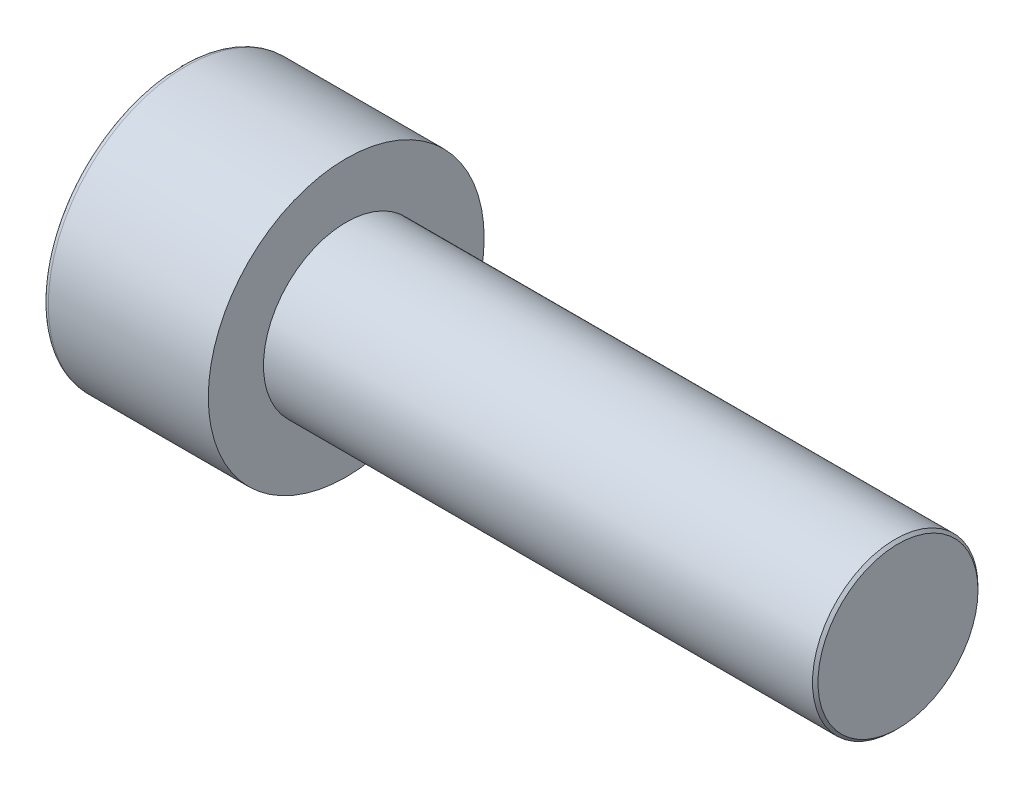
from build123d import *

# Parameters (mm, degrees)
SKETCH1_R           = 5
BASEHEAD_DEPTH      = 6
SKETCH2_R           = 3
BASEBODY_DEPTH      = 20
HEXAGONSOCKET_DEPTH = 3
TOPFILLET_R         = 0.2
CHAMFER1_SIZE       = 0.1


with BuildPart() as part:
    # Sketch1 → BaseHead (new body)
    with BuildSketch(Plane(origin=(0, 0, 0), x_dir=(0, 0, -1), z_dir=(1, 0, 0))):
        Circle(SKETCH1_R)
    extrude(amount=BASEHEAD_DEPTH)

    # Sketch2 → BaseBody (add)
    with BuildSketch(Plane(origin=(6, 0, 0), x_dir=(0, 0, -1), z_dir=(1, 0, 0))):
        Circle(SKETCH2_R)
    extrude(amount=BASEBODY_DEPTH)

    # Sketch3 → HexagonSocket (cut)
    with BuildSketch(Plane(origin=(0, 0, 0), x_dir=(0, 0, -1), z_dir=(1, 0, 0))):
        Polygon((2.886751346, 0), (1.443375673, 2.5), (-1.443375673, 2.5), (-2.886751346, 0), (-1.443375673, -2.5), (1.443375673, -2.5), align=None)
    extrude(amount=HEXAGONSOCKET_DEPTH, mode=Mode.SUBTRACT)

    # Sketch4 → Cut-Revolve1 (revolve, cut)
    with BuildSketch(Plane(origin=(-4.19613823, 0.75, 0), x_dir=(-1, 0, 0), z_dir=(0, 0, 1))):
        Polygon((-7.19613823, 3.25), (-8.639513903, 0.75), (-7.19613823, 0.75), align=None)
    revolve(axis=Axis((0.838992387, 0, 0), (-1, 0, 0)), mode=Mode.SUBTRACT)

    # TopFillet
    topfillet_edges = [part.edges().sort_by_distance(p)[0] for p in [
        (0, 0, 5),
    ]]
    fillet(topfillet_edges, radius=TOPFILLET_R)

    # Chamfer1
    chamfer1_edges = [part.edges().sort_by_distance(p)[0] for p in [
        (26, 0, 3),
    ]]
    chamfer(chamfer1_edges, length=CHAMFER1_SIZE)


solid = part.part
